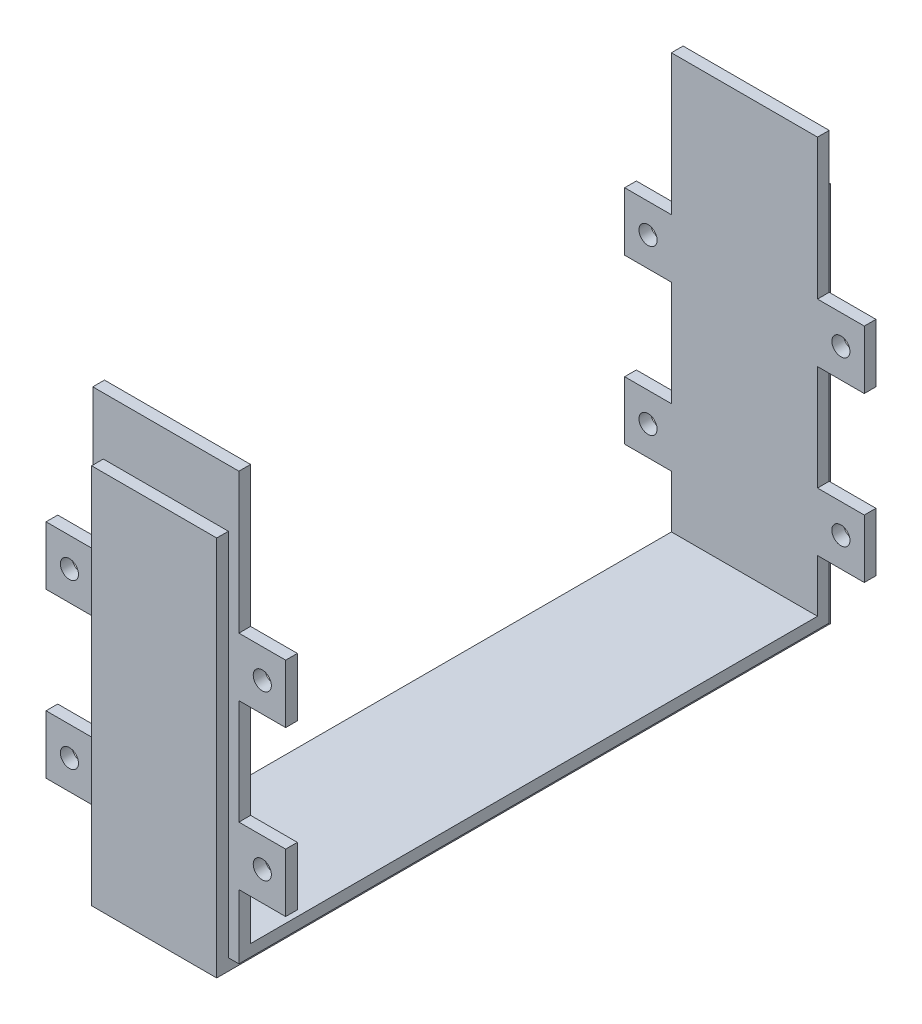
from build123d import *

# Parameters (mm, degrees)
SKETCH1_W           = 105
SKETCH1_H           = 4
SKETCH1_W_2         = 2
SKETCH1_H_2         = 9.8
BOSS_EXTRUDE1_DEPTH = 12.5
SKETCH2_W           = 8
SKETCH2_H           = 10
SKETCH2_R           = 1.55
BOSS_EXTRUDE2_DEPTH = 2
SKETCH4_W           = 8
SKETCH4_H           = 10
SKETCH4_R           = 1.55
BOSS_EXTRUDE3_DEPTH = 2
SKETCH5_W           = 101
SKETCH5_H           = 2
CUT_EXTRUDE1_DEPTH  = 1.8
SKETCH6_W           = 101
SKETCH6_H           = 2
CUT_EXTRUDE2_DEPTH  = 1.8


with BuildPart() as part:
    # Sketch1 → Boss-Extrude1 (new body, symmetric)
    with BuildSketch(Plane(origin=(0, 0, 0), x_dir=(0, 0, -1), z_dir=(1, 0, 0))):
        Rectangle(SKETCH1_W, SKETCH1_H)
        Polygon((-52.5, 63.2), (-52.5, 2), (-48.5, 2), (-48.5, 63.2), (-50.5, 63.2), align=None)
        Polygon((48.5, 63.2), (48.5, 2), (52.5, 2), (52.5, 63.2), (50.5, 63.2), align=None)
        with Locations((-49.5, 68.1)):
            Rectangle(SKETCH1_W_2, SKETCH1_H_2)
        with Locations((49.5, 68.1)):
            Rectangle(SKETCH1_W_2, SKETCH1_H_2)
    extrude(amount=BOSS_EXTRUDE1_DEPTH, both=True)

    # Sketch2 → Boss-Extrude2 (add)
    with BuildSketch(Plane.XY.offset(-48.5)):
        with Locations((-16.5, 16)):
            Rectangle(SKETCH2_W, SKETCH2_H)
        with Locations((-16.5, 16)):
            Circle(SKETCH2_R, mode=Mode.SUBTRACT)
        with Locations((-16.5, 44)):
            Rectangle(SKETCH2_W, SKETCH2_H)
        with Locations((-16.5, 44)):
            Circle(SKETCH2_R, mode=Mode.SUBTRACT)
        with Locations((16.5, 16)):
            Rectangle(SKETCH2_W, SKETCH2_H)
        with Locations((16.5, 16)):
            Circle(SKETCH2_R, mode=Mode.SUBTRACT)
        with Locations((16.5, 44)):
            Rectangle(SKETCH2_W, SKETCH2_H)
        with Locations((16.5, 44)):
            Circle(SKETCH2_R, mode=Mode.SUBTRACT)
    extrude(amount=-BOSS_EXTRUDE2_DEPTH)

    # Sketch4 → Boss-Extrude3 (add)
    with BuildSketch(Plane(origin=(0, 0, 48.5), x_dir=(-1, 0, 0), z_dir=(0, 0, -1))):
        with Locations((-16.5, 16)):
            Rectangle(SKETCH4_W, SKETCH4_H)
        with Locations((-16.5, 16)):
            Circle(SKETCH4_R, mode=Mode.SUBTRACT)
        with Locations((-16.5, 44)):
            Rectangle(SKETCH4_W, SKETCH4_H)
        with Locations((-16.5, 44)):
            Circle(SKETCH4_R, mode=Mode.SUBTRACT)
        with Locations((16.5, 16)):
            Rectangle(SKETCH4_W, SKETCH4_H)
        with Locations((16.5, 16)):
            Circle(SKETCH4_R, mode=Mode.SUBTRACT)
        with Locations((16.5, 44)):
            Rectangle(SKETCH4_W, SKETCH4_H)
        with Locations((16.5, 44)):
            Circle(SKETCH4_R, mode=Mode.SUBTRACT)
    extrude(amount=-BOSS_EXTRUDE3_DEPTH)

    # Sketch5 → Cut-Extrude1 (cut)
    with BuildSketch(Plane.ZY.offset(12.5)):
        Polygon((-50.5, 63.2), (-52.5, 63.2), (-52.5, -2), (-50.5, -2), (-50.5, 0), (-50.5, 11), (-50.5, 21), (-50.5, 39), (-50.5, 49), align=None)
        with Locations((0, -1)):
            Rectangle(SKETCH5_W, SKETCH5_H)
        Polygon((50.5, 0), (50.5, -2), (52.5, -2), (52.5, 63.2), (50.5, 63.2), (50.5, 49), (50.5, 39), (50.5, 21), (50.5, 11), align=None)
    extrude(amount=-CUT_EXTRUDE1_DEPTH, mode=Mode.SUBTRACT)

    # Sketch6 → Cut-Extrude2 (cut)
    with BuildSketch(Plane(origin=(12.5, 0, 0), x_dir=(0, 0, -1), z_dir=(1, 0, 0))):
        Polygon((-50.5, 0), (-50.5, 63.2), (-52.5, 63.2), (-52.5, -2), (-50.5, -2), align=None)
        with Locations((0, -1)):
            Rectangle(SKETCH6_W, SKETCH6_H)
        Polygon((50.5, 63.2), (50.5, 0), (50.5, -2), (52.5, -2), (52.5, 63.2), align=None)
    extrude(amount=-CUT_EXTRUDE2_DEPTH, mode=Mode.SUBTRACT)


solid = part.part
